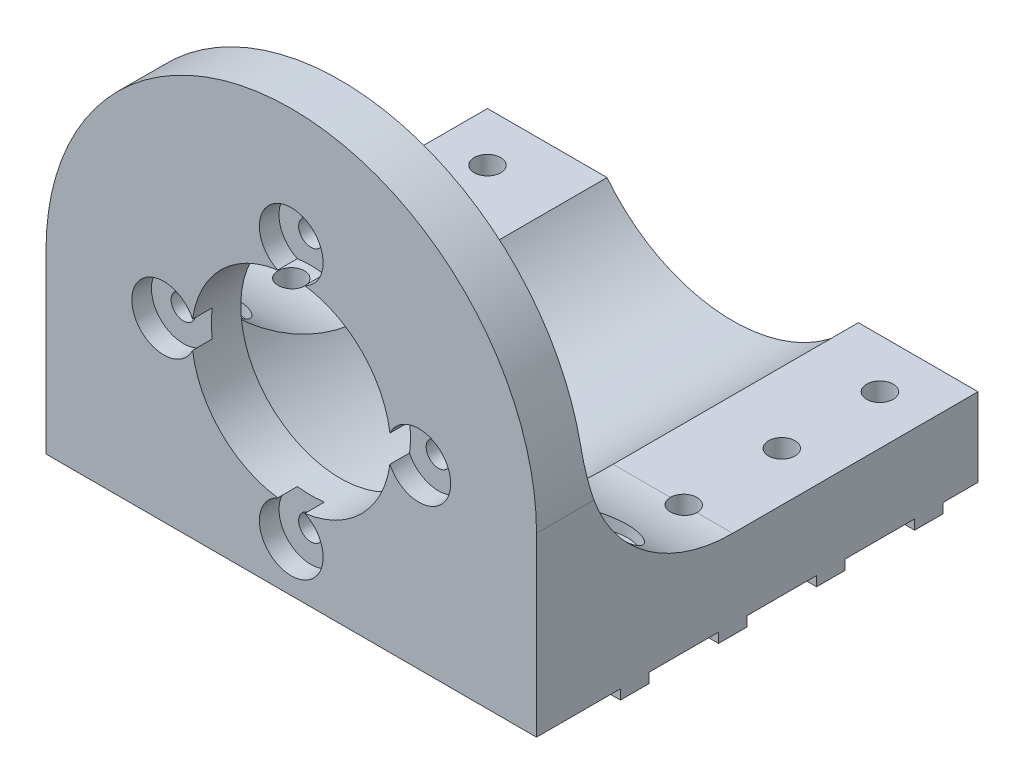
from build123d import *

# Parameters (mm, degrees)
SKETCH1_R                  = 10.15
MAIN_DEPTH                 = 45
SKETCH3_R                  = 16.25
MOTOREDUCTORMAINHOLE_DEPTH = 40
SKETCH2_R                  = 1.25
FIXHOLEMOTORS_DEPTH        = 10
HOLECIRCULARPATTERN_COUNT  = 4
SKETCH5_R                  = 3.25
HEADSCREWHOLE_DEPTH        = 2
SKETCH4_W                  = 50
SKETCH4_H                  = 35
HORIZONTALCUT_DEPTH        = 40
FILLET3_R                  = 15
SKETCH7_W                  = 50
SKETCH7_H                  = 2.9
MAKERBEAMRAIL_DEPTH        = 1
LPATTERN1_COUNT            = 4
LPATTERN1_PITCH            = 10
SKETCH6_R                  = 1.35
FIXTOPLATEHOLE_DEPTH       = 45.0000001
SKETCH9_R                  = 4.25
CUT_EXTRUDE2_DEPTH         = 36.0000001


with BuildPart() as part:
    # Sketch1 → Main (new body)
    with BuildSketch(Plane.XY):
        with BuildLine():
            Line((-25, -18), (-25, 0))
            ThreePointArc((-25, 0), (0, 25), (25, 0))
            Line((25, 0), (25, -18))
            Line((25, -18), (-25, -18))
        make_face()
        Circle(SKETCH1_R, mode=Mode.SUBTRACT)
    extrude(amount=MAIN_DEPTH)

    # Sketch3 → MotoReductorMainHole (cut)
    with BuildSketch(Plane.XY):
        Circle(SKETCH3_R)
    extrude(amount=MOTOREDUCTORMAINHOLE_DEPTH, mode=Mode.SUBTRACT)

    # Sketch2 → FixHoleMotors (cut)
    with BuildSketch(Plane.XY.offset(45)):
        with Locations((0, 13)):
            Circle(SKETCH2_R)
    fixholemotors = extrude(amount=-FIXHOLEMOTORS_DEPTH, mode=Mode.SUBTRACT)

    # HoleCircularPattern: FixHoleMotors ×4 about axis
    holecircularpattern_axis = Axis((0, 0, 0), (0, 0, 1))
    for i in range(1, HOLECIRCULARPATTERN_COUNT):
        add(fixholemotors.rotate(holecircularpattern_axis, i * 360 / HOLECIRCULARPATTERN_COUNT), mode=Mode.SUBTRACT)

    # Sketch5 → HeadScrewHole (cut)
    with BuildSketch(Plane.XY.offset(45)):
        with Locations((0, 13)):
            Circle(SKETCH5_R)
        with Locations((13, 0)):
            Circle(SKETCH5_R)
        with Locations((0, -13)):
            Circle(SKETCH5_R)
        with Locations((-13, 0)):
            Circle(SKETCH5_R)
    extrude(amount=-HEADSCREWHOLE_DEPTH, mode=Mode.SUBTRACT)

    # Sketch4 → HorizontalCut (cut)
    with BuildSketch(Plane(origin=(0, 0, 0), x_dir=(-1, 0, 0), z_dir=(0, 0, -1))):
        with Locations((0, 7.5)):
            Rectangle(SKETCH4_W, SKETCH4_H)
    extrude(amount=-HORIZONTALCUT_DEPTH, mode=Mode.SUBTRACT)

    # Fillet3
    fillet3_edges = [part.edges().sort_by_distance(p)[0] for p in [
        (-18.904344229, -10, 40),
        (18.904344229, -10, 40),
    ]]
    fillet(fillet3_edges, radius=FILLET3_R)

    # Sketch7 → MakerBeamRail (add)
    with BuildSketch(Plane(origin=(0, -18, 0), x_dir=(-1, 0, 0), z_dir=(0, -1, 0))):
        with Locations((0, -35)):
            Rectangle(SKETCH7_W, SKETCH7_H)
    makerbeamrail = extrude(amount=MAKERBEAMRAIL_DEPTH)

    # LPattern1: MakerBeamRail ×4
    with Locations(*[(0, 0, -i * LPATTERN1_PITCH) for i in range(1, LPATTERN1_COUNT)]):
        add(makerbeamrail)

    # Sketch6 → FixToPlateHole (cut, through all)
    with BuildSketch(Plane(origin=(0, -19, 0), x_dir=(-1, 0, 0), z_dir=(0, -1, 0))):
        with Locations((20, -35)):
            Circle(SKETCH6_R)
        with Locations((20, -15)):
            Circle(SKETCH6_R)
        with Locations((20, -25)):
            Circle(SKETCH6_R)
        with Locations((20, -5)):
            Circle(SKETCH6_R)
    fixtoplatehole = extrude(amount=-FIXTOPLATEHOLE_DEPTH, mode=Mode.SUBTRACT)

    # Sketch9 → Cut-Extrude2 (cut, through all)
    with BuildSketch(Plane(origin=(0, -10, 0), x_dir=(1, 0, 0), z_dir=(0, 1, 0))):
        with Locations((-20, -35)):
            Circle(SKETCH9_R)
    cut_extrude2 = extrude(amount=CUT_EXTRUDE2_DEPTH, mode=Mode.SUBTRACT)

    # Mirror1: FixToPlateHole, Cut-Extrude2 across plane
    add(fixtoplatehole.mirror(Plane(origin=(0, 0, 0), x_dir=(0, 0, 1), z_dir=(1, 0, 0))), mode=Mode.SUBTRACT)
    add(cut_extrude2.mirror(Plane(origin=(0, 0, 0), x_dir=(0, 0, 1), z_dir=(1, 0, 0))), mode=Mode.SUBTRACT)


solid = part.part
